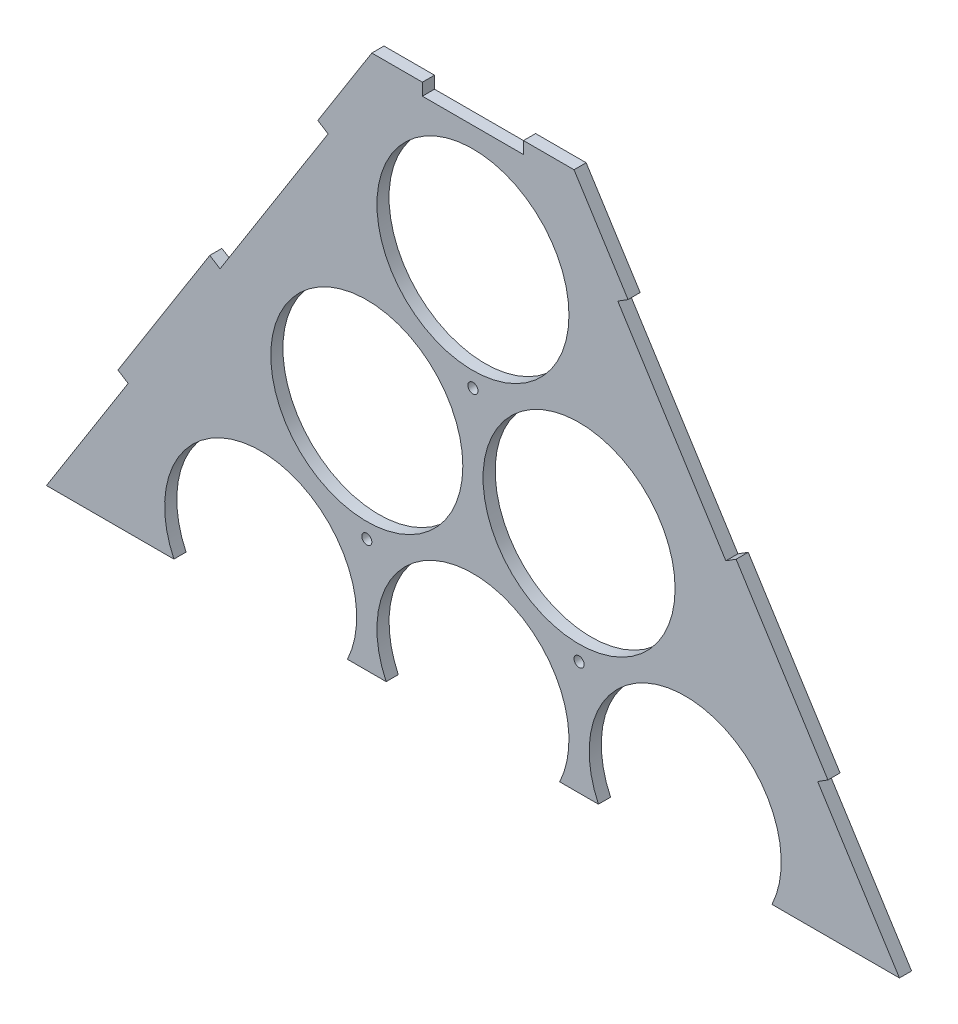
from build123d import *

# Parameters (mm, degrees)
ESQUISSE1_R             = 47.5
BOSS_EXTRU_1_DEPTH      = 6
ESQUISSE9_W             = 150
ESQUISSE9_H             = 120
BOSS_EXTRU_2_DEPTH      = 10
ESQUISSE10_W            = 6
ESQUISSE10_H            = 50
ESQUISSE10_W_2          = 50
ESQUISSE10_H_2          = 6
ENL_V_MAT_EXTRU_1_DEPTH = 10
ESQUISSE11_W            = 670.254020464
ESQUISSE11_H            = 265.771999275
ENL_V_MAT_EXTRU_2_DEPTH = 10
ESQUISSE12_R            = 2.5
ENL_V_MAT_EXTRU_3_DEPTH = 10


with BuildPart() as part:
    # Esquisse1 → Boss.-Extru.1 (new body)
    with BuildSketch(Plane.XY):
        Polygon((-255.775862069, 10.959681362), (-205, -75.190256718), (205, -75.190256718), (255.775862069, 10.959681362), (50, 336.353741833), (-50, 336.353741833), align=None)
        with Locations((-157.5, 0)):
            Circle(ESQUISSE1_R, mode=Mode.SUBTRACT)
        with Locations((-52.5, 0)):
            Circle(ESQUISSE1_R, mode=Mode.SUBTRACT)
        with Locations((52.5, 0)):
            Circle(ESQUISSE1_R, mode=Mode.SUBTRACT)
        with Locations((157.5, 0)):
            Circle(ESQUISSE1_R, mode=Mode.SUBTRACT)
        with Locations((-105, 90.932667397)):
            Circle(ESQUISSE1_R, mode=Mode.SUBTRACT)
        with Locations((0, 90.932667397)):
            Circle(ESQUISSE1_R, mode=Mode.SUBTRACT)
        with Locations((105, 90.932667397)):
            Circle(ESQUISSE1_R, mode=Mode.SUBTRACT)
        with Locations((-52.5, 181.865334795)):
            Circle(ESQUISSE1_R, mode=Mode.SUBTRACT)
        with Locations((52.5, 181.865334795)):
            Circle(ESQUISSE1_R, mode=Mode.SUBTRACT)
        with Locations((0, 272.798002192)):
            Circle(ESQUISSE1_R, mode=Mode.SUBTRACT)
    extrude(amount=BOSS_EXTRU_1_DEPTH)

    # Esquisse9 → Boss.-Extru.2 (add)
    with BuildSketch(Plane.XY.offset(6)):
        with Locations((0, -135.190256718)):
            Rectangle(ESQUISSE9_W, ESQUISSE9_H)
    extrude(amount=-BOSS_EXTRU_2_DEPTH)

    # Esquisse10 → Enlèv. mat.-Extru.1 (cut)
    with BuildSketch(Plane.XY.offset(6)):
        with Locations((-72, -129.244737692)):
            Rectangle(ESQUISSE10_W, ESQUISSE10_H)
        with Locations((0, -192.190256718)):
            Rectangle(ESQUISSE10_W_2, ESQUISSE10_H_2)
        with Locations((-140, -72.190256718)):
            Rectangle(ESQUISSE10_W_2, ESQUISSE10_H_2)
        Polygon((-217.693965517, -53.652772198), (-212.524969232, -50.606220473), (-237.912900267, -7.531251434), (-243.081896552, -10.577803158), align=None)
        Polygon((-229.051724138, 53.218650255), (-223.980647871, 50.011753703), (-170.532372009, 134.529691487), (-175.603448276, 137.736588039), align=None)
        Polygon((-130.172413793, 209.576835156), (-125.101337526, 206.369938604), (-71.653061664, 290.887876389), (-76.724137931, 294.094772941), align=None)
        with Locations((0, 333.353741833)):
            Rectangle(ESQUISSE10_W_2, ESQUISSE10_H_2)
        Polygon((71.653061664, 290.887876389), (76.724137931, 294.094772941), (130.172413793, 209.576835156), (125.101337526, 206.369938604), align=None)
        Polygon((170.532372009, 134.529691487), (175.603448276, 137.736588039), (229.051724138, 53.218650255), (223.980647871, 50.011753703), align=None)
        Polygon((237.912900267, -7.531251434), (243.081896552, -10.577803158), (217.693965517, -53.652772198), (212.524969232, -50.606220473), align=None)
        with Locations((140, -72.190256718)):
            Rectangle(ESQUISSE10_W_2, ESQUISSE10_H_2)
        with Locations((72, -129.244737692)):
            Rectangle(ESQUISSE10_W, ESQUISSE10_H)
    extrude(amount=-ENL_V_MAT_EXTRU_1_DEPTH, mode=Mode.SUBTRACT)

    # Esquisse11 → Enlèv. mat.-Extru.2 (cut)
    with BuildSketch(Plane.XY.offset(6)):
        with Locations((-20.35830969, -62.304257081)):
            Rectangle(ESQUISSE11_W, ESQUISSE11_H)
    extrude(amount=-ENL_V_MAT_EXTRU_2_DEPTH, mode=Mode.SUBTRACT)

    # Esquisse12 → Enlèv. mat.-Extru.3 (cut)
    with BuildSketch(Plane.XY.offset(6)):
        with Locations((-52.5, 126.865334795)):
            Circle(ESQUISSE12_R)
        with Locations((52.5, 126.865334795)):
            Circle(ESQUISSE12_R)
        with Locations((0, 217.798002192)):
            Circle(ESQUISSE12_R)
    extrude(amount=-ENL_V_MAT_EXTRU_3_DEPTH, mode=Mode.SUBTRACT)


solid = part.part
